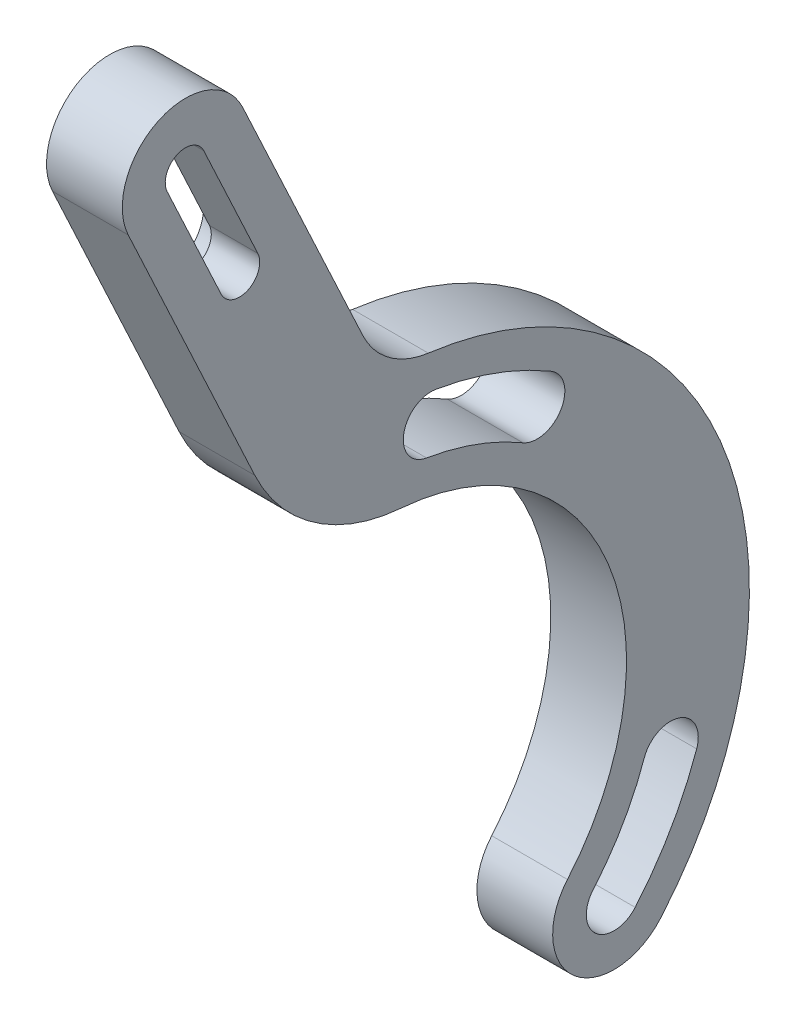
from build123d import *

# Parameters (mm, degrees)
BOSS_EXTRUDE1_DEPTH = 9
FILLET1_R           = 10
CUT_EXTRUDE1_DEPTH  = 3.25


with BuildPart() as part:
    # Sketch2 → Boss-Extrude1 (new body)
    with BuildSketch(Plane(origin=(0, 0, 0), x_dir=(0, 0, -1), z_dir=(1, 0, 0))):
        with BuildLine():
            Line((-30.009207192, 73.421599264), (-14.966983891, 41.163447295))
            ThreePointArc((-14.966983891, 41.163447295), (-7.925043754, 32.797065521), (2.36792839, 29.103829905))
            ThreePointArc((2.36792839, 29.103829905), (26.999530596, 11.120492238), (22.178254162, -18.993815897))
            ThreePointArc((22.178254162, -18.993815897), (22.974363729, -29.286833411), (33.267381244, -28.490723845))
            ThreePointArc((33.267381244, -28.490723845), (39.862888041, 18.149108987), (0.354910699, 43.798562059))
            Line((0.354910699, 43.798562059), (-16.414590386, 79.76087319))
            ThreePointArc((-16.414590386, 79.76087319), (-26.381535752, 83.388544629), (-30.009207192, 73.421599264))
        make_face()
        with BuildLine():
            ThreePointArc((-14.612962522, 63.829641692), (-15.773817383, 60.640219175), (-18.9632399, 61.801074036))
            Line((-18.9632399, 61.801074036), (-25.387037478, 75.576952399))
            ThreePointArc((-25.387037478, 75.576952399), (-24.226182617, 78.766374916), (-21.0367601, 77.605520055))
            Line((-21.0367601, 77.605520055), (-14.612962522, 63.829641692))
        make_face(mode=Mode.SUBTRACT)
        with BuildLine():
            ThreePointArc((5.435407174, 32.75204343), (2.720199354, 36.547784002), (6.515939926, 39.262991823))
            ThreePointArc((6.515939926, 39.262991823), (13.612401704, 37.399766307), (20.246265091, 34.265562156))
            ThreePointArc((20.246265091, 34.265562156), (21.408669119, 29.745737284), (16.888844247, 28.583333256))
            ThreePointArc((16.888844247, 28.583333256), (11.355068758, 31.19779501), (5.435407174, 32.75204343))
        make_face(mode=Mode.SUBTRACT)
        with BuildLine():
            ThreePointArc((30.229264235, -25.888831256), (25.576256317, -26.248716403), (25.216371171, -21.595708485))
            ThreePointArc((25.216371171, -21.595708485), (28.752043406, -16.6), (31.310617746, -11.040163783))
            ThreePointArc((31.310617746, -11.040163783), (35.52018338, -9.025329503), (37.53501766, -13.234895137))
            ThreePointArc((37.53501766, -13.234895137), (34.467811071, -19.9), (30.229264235, -25.888831256))
        make_face(mode=Mode.SUBTRACT)
    extrude(amount=BOSS_EXTRUDE1_DEPTH)

    # Fillet1
    fillet1_edges = [part.edges().sort_by_distance(p)[0] for p in [
        (4.5, 43.798562059, -0.354910699),
    ]]
    fillet(fillet1_edges, radius=FILLET1_R)

    # Sketch3 → Cut-Extrude1 (cut)
    with BuildSketch(Plane.ZY):
        with BuildLine():
            Line((21.093063199, 60.80792112), (27.516860778, 74.583799483))
            ThreePointArc((27.516860778, 74.583799483), (25.219335532, 80.896198215), (18.906936801, 78.59867297))
            Line((18.906936801, 78.59867297), (12.483139222, 64.822794607))
            ThreePointArc((12.483139222, 64.822794607), (14.780664468, 58.510395875), (21.093063199, 60.80792112))
        make_face()
    extrude(amount=-CUT_EXTRUDE1_DEPTH, mode=Mode.SUBTRACT)


solid = part.part
